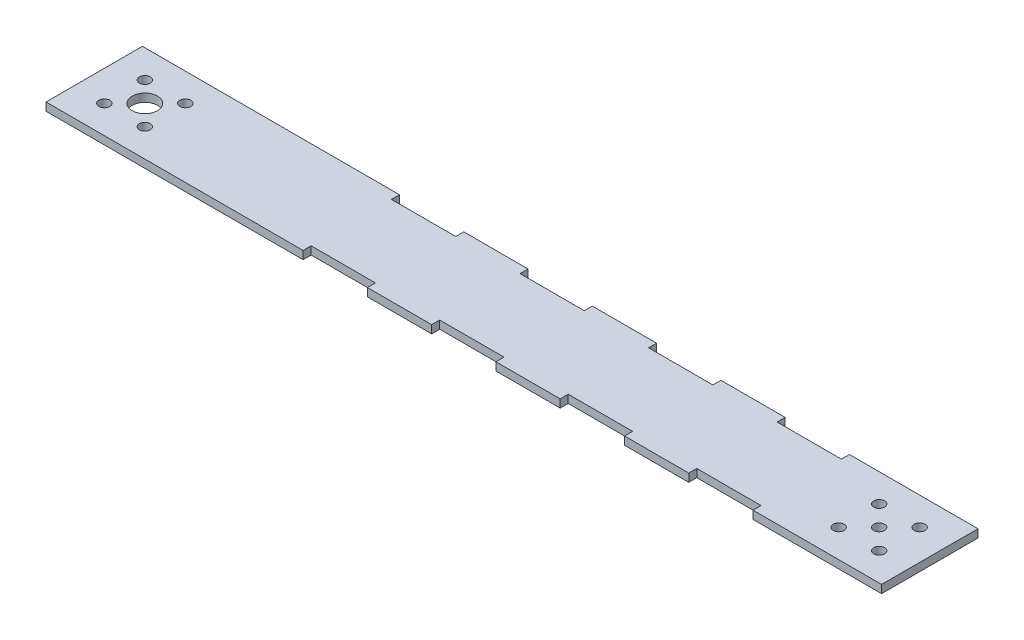
from build123d import *

# Parameters (mm, degrees)
SKETCH1_R           = 2.15
SKETCH1_R_2         = 5
BOSS_EXTRUDE1_DEPTH = 1.5875


with BuildPart() as part:
    # Sketch1 → Boss-Extrude1 (new body, symmetric)
    with BuildSketch(Plane(origin=(0, 0, 0), x_dir=(1, 0, 0), z_dir=(0, 1, 0))):
        Polygon((-20, 19.05), (-20, -19.05), (81.6, -19.05), (81.6, -15.875), (107, -15.875), (107, -19.05), (132.4, -19.05), (132.4, -15.875), (157.8, -15.875), (157.8, -19.05), (183.2, -19.05), (183.2, -15.875), (208.6, -15.875), (208.6, -19.05), (234, -19.05), (234, -15.875), (259.4, -15.875), (259.4, -19.05), (310.2, -19.05), (310.2, 19.05), (259.4, 19.05), (259.4, 15.875), (234, 15.875), (234, 19.05), (208.6, 19.05), (208.6, 15.875), (183.2, 15.875), (183.2, 19.05), (157.8, 19.05), (157.8, 15.875), (132.4, 15.875), (132.4, 19.05), (107, 19.05), (107, 15.875), (81.6, 15.875), (81.6, 19.05), align=None)
        with Locations((-8, -8)):
            Circle(SKETCH1_R, mode=Mode.SUBTRACT)
        with Locations((8, -8)):
            Circle(SKETCH1_R, mode=Mode.SUBTRACT)
        with Locations((282.2, -8)):
            Circle(SKETCH1_R, mode=Mode.SUBTRACT)
        with Locations((298.2, -8)):
            Circle(SKETCH1_R, mode=Mode.SUBTRACT)
        Circle(SKETCH1_R_2, mode=Mode.SUBTRACT)
        with Locations((-8, 8)):
            Circle(SKETCH1_R, mode=Mode.SUBTRACT)
        with Locations((8, 8)):
            Circle(SKETCH1_R, mode=Mode.SUBTRACT)
        with Locations((290.2, 0)):
            Circle(SKETCH1_R, mode=Mode.SUBTRACT)
        with Locations((282.2, 8)):
            Circle(SKETCH1_R, mode=Mode.SUBTRACT)
        with Locations((298.2, 8)):
            Circle(SKETCH1_R, mode=Mode.SUBTRACT)
    extrude(amount=BOSS_EXTRUDE1_DEPTH, both=True)


solid = part.part
